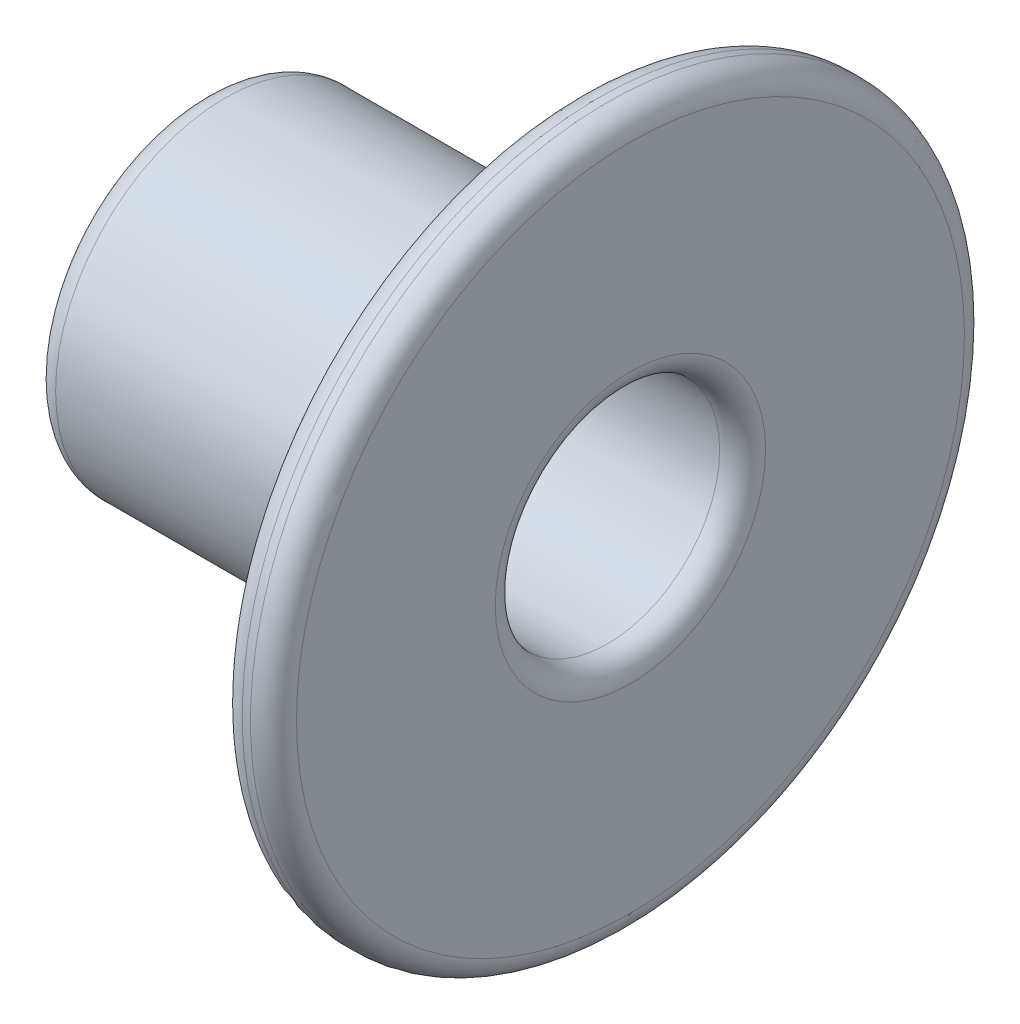
from build123d import *


with BuildPart() as part:
    # 草图1 → 旋转1 (revolve)
    with BuildSketch(Plane.XY):
        with BuildLine():
            Line((-455, 8.382), (-455, 0.277))
            Line((-455, 0.277), (-450, 0.277))
            Line((-450, 0.277), (-450, 6.477))
            Line((-450, 6.477), (-432.612413979, 6.477))
            ThreePointArc((-432.612413979, 6.477), (-431.714388367, 6.848974388), (-431.342413979, 7.747))
            Line((-431.342413979, 7.747), (-431.342413979, 18.73))
            ThreePointArc((-431.342413979, 18.73), (-431.714388367, 19.628025612), (-432.612413979, 20))
            Line((-432.612413979, 20), (-433.072413979, 20))
            ThreePointArc((-433.072413979, 20), (-433.970439591, 19.628025612), (-434.342413979, 18.73))
            Line((-434.342413979, 18.73), (-434.342413979, 11.652))
            ThreePointArc((-434.342413979, 11.652), (-434.928200417, 10.237786438), (-436.342413979, 9.652))
            Line((-436.342413979, 9.652), (-453.73, 9.652))
            ThreePointArc((-453.73, 9.652), (-454.628025612, 9.280025612), (-455, 8.382))
        make_face()
    revolve(axis=Axis((-455.001250002, 0.277, 0), (1, 0, 0)))


solid = part.part
